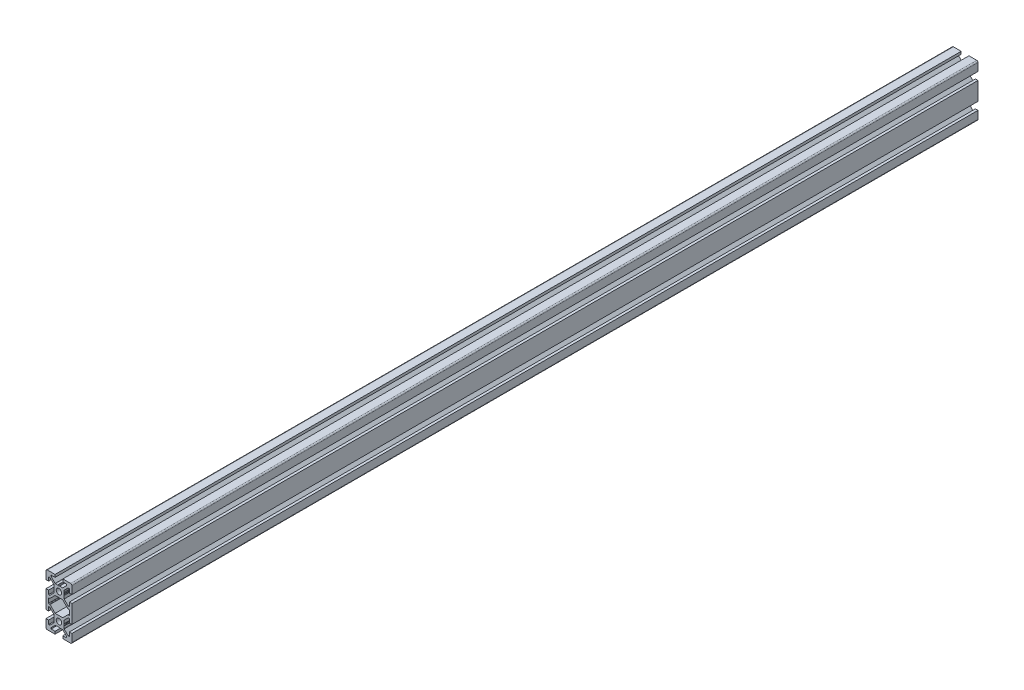
from build123d import *

# Parameters (mm, degrees)
SKETCH1_R           = 2.1
BOSS_EXTRUDE1_DEPTH = 700
SKETCH2_R           = 2
CUT_EXTRUDE1_DEPTH  = 21


with BuildPart() as part:
    # Sketch1 → Boss-Extrude1 (new body)
    with BuildSketch(Plane(origin=(0, 0, -600), x_dir=(-1, 0, 0), z_dir=(0, 0, -1))):
        with BuildLine():
            Line((10, -7), (10, 7))
            Line((10, 7), (8, 7))
            Line((8, 7), (8, 4))
            Line((8, 4), (7.060660172, 4))
            Line((7.060660172, 4), (4, 7.060660172))
            Line((4, 7.060660172), (4, 7.5))
            Line((4, 7.5), (3.750976592, 8.781114371))
            Line((3.750976592, 8.781114371), (3.933012702, 9.096410162))
            ThreePointArc((3.933012702, 9.096410162), (4, 9.346410162), (3.933012702, 9.596410162))
            Line((3.933012702, 9.596410162), (3.7, 10))
            Line((3.7, 10), (3.933012702, 10.403589838))
            ThreePointArc((3.933012702, 10.403589838), (3.982962913, 10.524180316), (4, 10.653589838))
            Line((4, 10.653589838), (4, 12.939339828))
            Line((4, 12.939339828), (7.060660172, 16))
            Line((7.060660172, 16), (8, 16))
            Line((8, 16), (8, 13))
            Line((8, 13), (10, 13))
            Line((10, 13), (10, 19))
            ThreePointArc((10, 19), (9.707106781, 19.707106781), (9, 20))
            Line((9, 20), (3, 20))
            Line((3, 20), (3, 18))
            Line((3, 18), (6, 18))
            Line((6, 18), (6, 17.060660172))
            Line((6, 17.060660172), (2.939339828, 14))
            Line((2.939339828, 14), (2.5, 14))
            Line((2.5, 14), (1.218885629, 13.750976592))
            Line((1.218885629, 13.750976592), (0.903589838, 13.933012702))
            ThreePointArc((0.903589838, 13.933012702), (0.653589838, 14), (0.403589838, 13.933012702))
            Line((0.403589838, 13.933012702), (0, 13.7))
            Line((0, 13.7), (-0.403589838, 13.933012702))
            ThreePointArc((-0.403589838, 13.933012702), (-0.524180316, 13.982962913), (-0.653589838, 14))
            Line((-0.653589838, 14), (-2.939339828, 14))
            Line((-2.939339828, 14), (-6, 17.060660172))
            Line((-6, 17.060660172), (-6, 18))
            Line((-6, 18), (-3, 18))
            Line((-3, 18), (-3, 20))
            Line((-3, 20), (-9, 20))
            ThreePointArc((-9, 20), (-9.707106781, 19.707106781), (-10, 19))
            Line((-10, 19), (-10, 13))
            Line((-10, 13), (-8, 13))
            Line((-8, 13), (-8, 16))
            Line((-8, 16), (-7.060660172, 16))
            Line((-7.060660172, 16), (-4, 12.939339828))
            Line((-4, 12.939339828), (-4, 12.5))
            Line((-4, 12.5), (-3.750976592, 11.218885629))
            Line((-3.750976592, 11.218885629), (-3.933012702, 10.903589838))
            ThreePointArc((-3.933012702, 10.903589838), (-4, 10.653589838), (-3.933012702, 10.403589838))
            Line((-3.933012702, 10.403589838), (-3.7, 10))
            Line((-3.7, 10), (-3.933012702, 9.596410162))
            ThreePointArc((-3.933012702, 9.596410162), (-3.982962913, 9.475819684), (-4, 9.346410162))
            Line((-4, 9.346410162), (-4, 7.060660172))
            Line((-4, 7.060660172), (-7.060660172, 4))
            Line((-7.060660172, 4), (-8, 4))
            Line((-8, 4), (-8, 7))
            Line((-8, 7), (-10, 7))
            Line((-10, 7), (-10, -7))
            Line((-10, -7), (-8, -7))
            Line((-8, -7), (-8, -4))
            Line((-8, -4), (-7.060660172, -4))
            Line((-7.060660172, -4), (-4, -7.060660172))
            Line((-4, -7.060660172), (-4, -9.346410162))
            ThreePointArc((-4, -9.346410162), (-3.982962913, -9.475819684), (-3.933012702, -9.596410162))
            Line((-3.933012702, -9.596410162), (-3.7, -10))
            Line((-3.7, -10), (-3.933012702, -10.403589838))
            ThreePointArc((-3.933012702, -10.403589838), (-4, -10.653589838), (-3.933012702, -10.903589838))
            Line((-3.933012702, -10.903589838), (-3.750976592, -11.218885629))
            Line((-3.750976592, -11.218885629), (-4, -12.5))
            Line((-4, -12.5), (-4, -12.939339828))
            Line((-4, -12.939339828), (-7.060660172, -16))
            Line((-7.060660172, -16), (-8, -16))
            Line((-8, -16), (-8, -13))
            Line((-8, -13), (-10, -13))
            Line((-10, -13), (-10, -19))
            ThreePointArc((-10, -19), (-9.707106781, -19.707106781), (-9, -20))
            Line((-9, -20), (-3, -20))
            Line((-3, -20), (-3, -18))
            Line((-3, -18), (-6, -18))
            Line((-6, -18), (-6, -17.060660172))
            Line((-6, -17.060660172), (-2.939339828, -14))
            Line((-2.939339828, -14), (-0.653589838, -14))
            ThreePointArc((-0.653589838, -14), (-0.524180316, -13.982962913), (-0.403589838, -13.933012702))
            Line((-0.403589838, -13.933012702), (0, -13.7))
            Line((0, -13.7), (0.403589839, -13.933012702))
            ThreePointArc((0.403589839, -13.933012702), (0.653589839, -14), (0.903589838, -13.933012702))
            Line((0.903589838, -13.933012702), (1.218885629, -13.750976592))
            Line((1.218885629, -13.750976592), (2.5, -14))
            Line((2.5, -14), (2.939339828, -14))
            Line((2.939339828, -14), (6, -17.060660172))
            Line((6, -17.060660172), (6, -18))
            Line((6, -18), (3, -18))
            Line((3, -18), (3, -20))
            Line((3, -20), (9, -20))
            ThreePointArc((9, -20), (9.707106781, -19.707106781), (10, -19))
            Line((10, -19), (10, -13))
            Line((10, -13), (8, -13))
            Line((8, -13), (8, -16))
            Line((8, -16), (7.060660172, -16))
            Line((7.060660172, -16), (4, -12.939339828))
            Line((4, -12.939339828), (4, -10.653589838))
            ThreePointArc((4, -10.653589838), (3.982962913, -10.524180316), (3.933012702, -10.403589838))
            Line((3.933012702, -10.403589838), (3.7, -10))
            Line((3.7, -10), (3.933012702, -9.596410162))
            ThreePointArc((3.933012702, -9.596410162), (4, -9.346410162), (3.933012702, -9.096410162))
            Line((3.933012702, -9.096410162), (3.750976592, -8.781114371))
            Line((3.750976592, -8.781114371), (4, -7.5))
            Line((4, -7.5), (4, -7.060660172))
            Line((4, -7.060660172), (7.060660172, -4))
            Line((7.060660172, -4), (8, -4))
            Line((8, -4), (8, -7))
            Line((8, -7), (10, -7))
        make_face()
        with Locations((0, -10)):
            Circle(SKETCH1_R, mode=Mode.SUBTRACT)
        with Locations((0, 10)):
            Circle(SKETCH1_R, mode=Mode.SUBTRACT)
        with BuildLine():
            Line((8, 1.7), (8, -1.7))
            ThreePointArc((8, -1.7), (7.912132034, -1.912132034), (7.7, -2))
            Line((7.7, -2), (7.063603897, -2))
            ThreePointArc((7.063603897, -2), (6.948798867, -2.02283614), (6.851471863, -2.087867966))
            Line((6.851471863, -2.087867966), (2.939339828, -6))
            Line((2.939339828, -6), (-2.939339828, -6))
            Line((-2.939339828, -6), (-6.851471863, -2.087867966))
            ThreePointArc((-6.851471863, -2.087867966), (-6.948798867, -2.02283614), (-7.063603897, -2))
            Line((-7.063603897, -2), (-7.7, -2))
            ThreePointArc((-7.7, -2), (-7.912132034, -1.912132034), (-8, -1.7))
            Line((-8, -1.7), (-8, 1.7))
            ThreePointArc((-8, 1.7), (-7.912132034, 1.912132034), (-7.7, 2))
            Line((-7.7, 2), (-7.063603897, 2))
            ThreePointArc((-7.063603897, 2), (-6.948798867, 2.02283614), (-6.851471863, 2.087867966))
            Line((-6.851471863, 2.087867966), (-2.939339828, 6))
            Line((-2.939339828, 6), (2.939339828, 6))
            Line((2.939339828, 6), (6.851471863, 2.087867966))
            ThreePointArc((6.851471863, 2.087867966), (6.948798867, 2.02283614), (7.063603897, 2))
            Line((7.063603897, 2), (7.7, 2))
            ThreePointArc((7.7, 2), (7.912132034, 1.912132034), (8, 1.7))
        make_face(mode=Mode.SUBTRACT)
    extrude(amount=-BOSS_EXTRUDE1_DEPTH)

    # Sketch2 → Cut-Extrude1 (cut, through all)
    with BuildSketch(Plane.ZY.offset(10)):
        with Locations((90, 10)):
            Circle(SKETCH2_R)
        with Locations((90, -10)):
            Circle(SKETCH2_R)
    cut_extrude1 = extrude(amount=-CUT_EXTRUDE1_DEPTH, mode=Mode.SUBTRACT)

    # Mirror1: Cut-Extrude1 across plane
    add(cut_extrude1.mirror(Plane.XY.offset(-250)), mode=Mode.SUBTRACT)


solid = part.part
